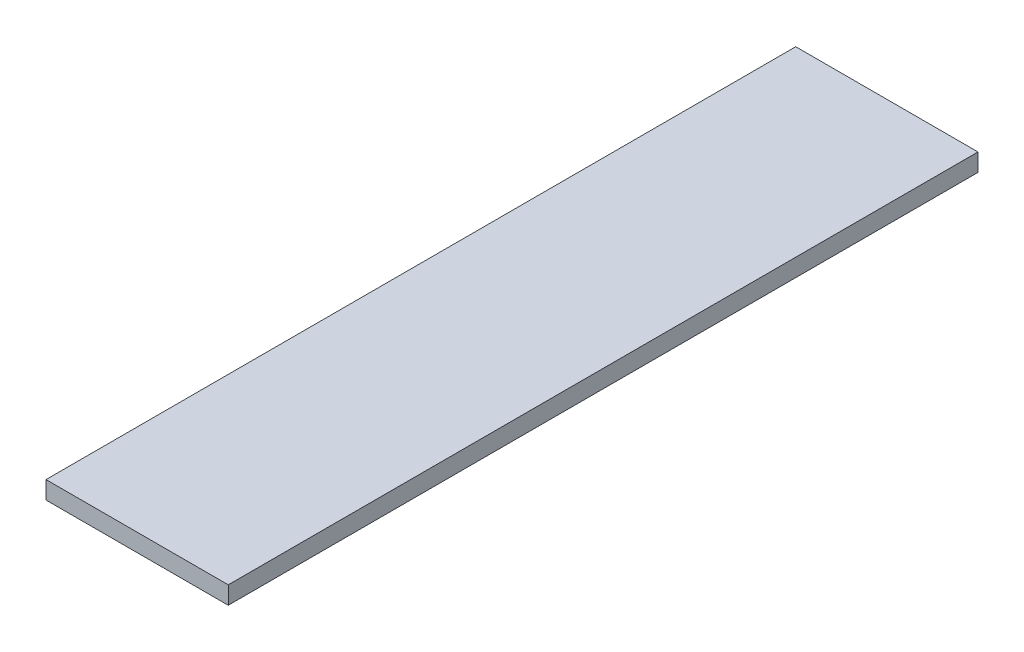
from build123d import *

# Parameters (mm, degrees)
SKETCH_1_W      = 185
SKETCH_1_H      = 761
EXTRUDE_1_DEPTH = 18


with BuildPart() as part:
    # Эскиз1 → Бобышка-Вытянуть1 (new body)
    with BuildSketch(Plane(origin=(0, 0, 0), x_dir=(1, 0, 0), z_dir=(0, 1, 0))):
        Rectangle(SKETCH_1_W, SKETCH_1_H)
    extrude(amount=EXTRUDE_1_DEPTH)


solid = part.part
